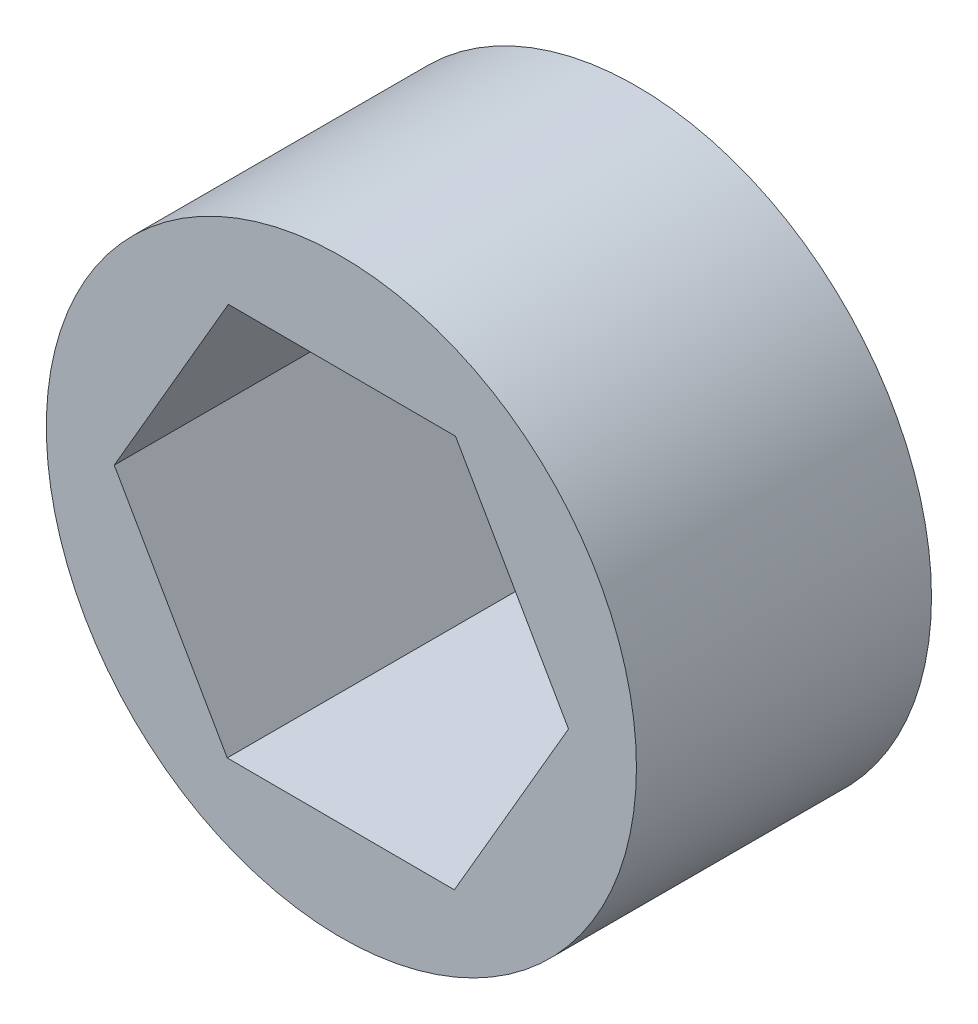
from build123d import *

# Parameters (mm, degrees)
SKETCH1_R           = 9.525
BOSS_EXTRUDE1_DEPTH = 9.525


with BuildPart() as part:
    # Sketch1 → Boss-Extrude1 (new body)
    with BuildSketch(Plane.XY):
        Circle(SKETCH1_R)
        Polygon((3.64699361, -6.361035367), (7.332315027, -0.022128569), (3.685321417, 6.338906797), (-3.64699361, 6.361035367), (-7.332315027, 0.022128569), (-3.685321417, -6.338906797), align=None, mode=Mode.SUBTRACT)
    extrude(amount=BOSS_EXTRUDE1_DEPTH)


solid = part.part
